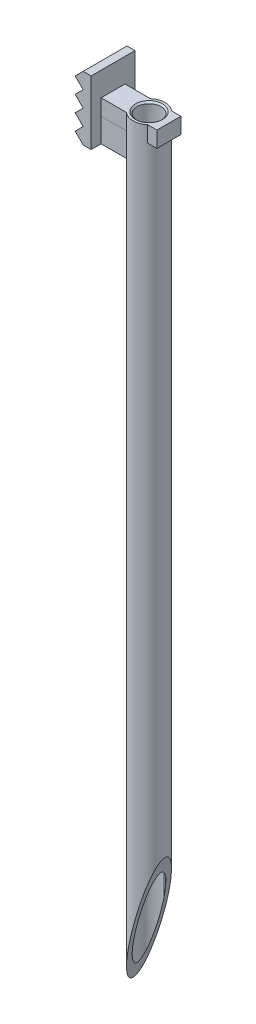
from build123d import *

# Parameters (mm, degrees)
SKETCH1_W                = 3.5
SKETCH1_H                = 1
BOSS_EXTRUDE3_DEPTH      = 0.75
SKETCH4_R                = 1
BOSS_EXTRUDE5_DEPTH      = 46.5
BOSS_EXTRUDE5_DEPTH_BACK = 1
SKETCH5_R                = 0.75
CUT_EXTRUDE1_DEPTH       = 18
SKETCH6_W                = 2.75
SKETCH6_H                = 4
BOSS_EXTRUDE6_DEPTH      = 1
CUT_EXTRUDE2_DEPTH       = 10
CUT_EXTRUDE4_DEPTH       = 2.75
CUT_EXTRUDE4_DEPTH_BACK  = 2
SKETCH10_R               = 0.75
CUT_EXTRUDE5_DEPTH       = 29
SKETCH11_R               = 0.4
BOSS_EXTRUDE7_DEPTH      = 1
SKETCH12_R               = 0.325
CUT_EXTRUDE6_DEPTH       = 35
FILLET1_R                = 0.025
FILLET2_R                = 0.025
FILLET3_R                = 0.25
FILLET4_R                = 0.1
SKETCH13_W               = 0.317975189
SKETCH13_H               = 1
BOSS_EXTRUDE8_DEPTH      = 0.375
SKETCH14_W               = 0.317975189
SKETCH14_H               = 1
BOSS_EXTRUDE9_DEPTH      = 0.375
BOSS_EXTRUDE10_REACH     = 6.182
SKETCH15_W               = 0.375
SKETCH15_H               = 1
BOSS_EXTRUDE11_REACH     = 6.182
SKETCH16_W               = 0.375
SKETCH16_H               = 1
SKETCH17_W               = 1.327975189
SKETCH17_H               = 1
BOSS_EXTRUDE12_DEPTH     = 0.375
BOSS_EXTRUDE13_REACH     = 4.172
SKETCH18_W               = 0.375
SKETCH18_H               = 1
SKETCH19_W               = 1.327975189
SKETCH19_H               = 1
BOSS_EXTRUDE14_DEPTH     = 0.375
BOSS_EXTRUDE15_REACH     = 4.172
SKETCH20_W               = 0.375
SKETCH20_H               = 1
BOSS_EXTRUDE16_DEPTH     = 1.5
CHAMFER1_SIZE            = 0.1


with BuildPart() as part:
    # Sketch1 → Boss-Extrude3 (new body)
    with BuildSketch(Plane.XY):
        with Locations((1.75, 0.5)):
            Rectangle(SKETCH1_W, SKETCH1_H)
    extrude(amount=BOSS_EXTRUDE3_DEPTH)

    # Sketch4 → Boss-Extrude5 (add, two sides)
    with BuildSketch(Plane.XZ) as boss_extrude5_sk:
        with Locations((2.255, 0.375)):
            Circle(SKETCH4_R)
    extrude(amount=BOSS_EXTRUDE5_DEPTH)
    extrude(boss_extrude5_sk.sketch, amount=-BOSS_EXTRUDE5_DEPTH_BACK)

    # Sketch5 → Cut-Extrude1 (cut)
    with BuildSketch(Plane.XZ.offset(46.5)):
        with Locations((2.255, 0.375)):
            Circle(SKETCH5_R)
    extrude(amount=-CUT_EXTRUDE1_DEPTH, mode=Mode.SUBTRACT)

    # Sketch6 → Boss-Extrude6 (add)
    with BuildSketch(Plane.ZY):
        with Locations((0.375, 0.5)):
            Rectangle(SKETCH6_W, SKETCH6_H)
    extrude(amount=BOSS_EXTRUDE6_DEPTH)

    # Sketch7 → Cut-Extrude2 (cut)
    with BuildSketch(Plane.XY.offset(1.75)):
        Polygon((-0.5, 2.5), (-1.357587954, 2.5), (-1.357587954, -1.5), (-0.5, -1.5), (-1, -1), (-0.5, -0.5), (-1, 0), (-0.5, 0.5), (-1, 1), (-0.5, 1.5), (-1, 2), align=None)
    extrude(amount=-CUT_EXTRUDE2_DEPTH, mode=Mode.SUBTRACT)

    # Sketch8 → Cut-Extrude4 (cut, two sides)
    with BuildSketch(Plane.XY) as cut_extrude4_sk:
        Polygon((1.255, -46.5), (3.255, -39), (3.255, -46.5), align=None)
    extrude(amount=CUT_EXTRUDE4_DEPTH, mode=Mode.SUBTRACT)
    extrude(cut_extrude4_sk.sketch, amount=-CUT_EXTRUDE4_DEPTH_BACK, mode=Mode.SUBTRACT)

    # Sketch10 → Cut-Extrude5 (cut)
    with BuildSketch(Plane(origin=(0, 1, 0), x_dir=(1, 0, 0), z_dir=(0, 1, 0))):
        with Locations((2.255, -0.375)):
            Circle(SKETCH10_R)
    extrude(amount=-CUT_EXTRUDE5_DEPTH, mode=Mode.SUBTRACT)

    # Sketch11 → Boss-Extrude7 (add)
    with BuildSketch(Plane(origin=(0, -28, 0), x_dir=(1, 0, 0), z_dir=(0, 1, 0))):
        with Locations((2.255, -0.375)):
            Circle(SKETCH11_R)
    extrude(amount=BOSS_EXTRUDE7_DEPTH)

    # Sketch12 → Cut-Extrude6 (cut)
    with BuildSketch(Plane(origin=(0, -27, 0), x_dir=(1, 0, 0), z_dir=(0, 1, 0))):
        with Locations((2.255, -0.375)):
            Circle(SKETCH12_R)
    extrude(amount=-CUT_EXTRUDE6_DEPTH, mode=Mode.SUBTRACT)

    # Fillet1
    fillet1_edges = [part.edges().sort_by_distance(p)[0] for p in [
        (1.93, -27, 0.375),
    ]]
    fillet(fillet1_edges, radius=FILLET1_R)

    # Fillet2
    fillet2_edges = [part.edges().sort_by_distance(p)[0] for p in [
        (1.855, -27, 0.375),
    ]]
    fillet(fillet2_edges, radius=FILLET2_R)

    # Fillet3
    fillet3_edges = [part.edges().sort_by_distance(p)[0] for p in [
        (1.505, -28.5, 0.375),
    ]]
    fillet(fillet3_edges, radius=FILLET3_R)

    # Fillet4
    fillet4_edges = [part.edges().sort_by_distance(p)[0] for p in [
        (1.93, -28.5, 0.375),
    ]]
    fillet(fillet4_edges, radius=FILLET4_R)

    # Sketch13 → Boss-Extrude8 (add)
    with BuildSketch(Plane(origin=(0, 0, 0), x_dir=(-1, 0, 0), z_dir=(0, 0, -1))):
        with Locations((-3.341012405, 0.5)):
            Rectangle(SKETCH13_W, SKETCH13_H)
    extrude(amount=BOSS_EXTRUDE8_DEPTH)

    # Sketch14 → Boss-Extrude9 (add)
    with BuildSketch(Plane.XY.offset(0.75)):
        with Locations((3.341012405, 0.5)):
            Rectangle(SKETCH14_W, SKETCH14_H)
    extrude(amount=BOSS_EXTRUDE9_DEPTH)

    # Sketch15 → Boss-Extrude10 (add, up to next)
    with BuildSketch(Plane.ZY.offset(-3.182024811), mode=Mode.PRIVATE) as boss_extrude10_sk1:
        with Locations((-0.1875, 0.5)):
            Rectangle(SKETCH15_W, SKETCH15_H)
    boss_extrude10_tool1 = extrude(boss_extrude10_sk1.sketch, amount=BOSS_EXTRUDE10_REACH, mode=Mode.PRIVATE) - part.part
    add(boss_extrude10_tool1.solids().sort_by_distance((3.182025, 0.5, -0.1875))[0])

    # Sketch16 → Boss-Extrude11 (add, up to next)
    with BuildSketch(Plane.ZY.offset(-3.182024811), mode=Mode.PRIVATE) as boss_extrude11_sk1:
        with Locations((0.9375, 0.5)):
            Rectangle(SKETCH16_W, SKETCH16_H)
    boss_extrude11_tool1 = extrude(boss_extrude11_sk1.sketch, amount=BOSS_EXTRUDE11_REACH, mode=Mode.PRIVATE) - part.part
    add(boss_extrude11_tool1.solids().sort_by_distance((3.182025, 0.5, 0.9375))[0])

    # Sketch17 → Boss-Extrude12 (add)
    with BuildSketch(Plane.XY.offset(0.75)):
        with Locations((0.663987595, 0.5)):
            Rectangle(SKETCH17_W, SKETCH17_H)
    extrude(amount=BOSS_EXTRUDE12_DEPTH)

    # Sketch18 → Boss-Extrude13 (add, up to next)
    with BuildSketch(Plane(origin=(1.327975189, 0, 0), x_dir=(0, 0, -1), z_dir=(1, 0, 0)), mode=Mode.PRIVATE) as boss_extrude13_sk1:
        with Locations((-0.9375, 0.5)):
            Rectangle(SKETCH18_W, SKETCH18_H)
    boss_extrude13_tool1 = extrude(boss_extrude13_sk1.sketch, amount=BOSS_EXTRUDE13_REACH, mode=Mode.PRIVATE) - part.part
    add(boss_extrude13_tool1.solids().sort_by_distance((1.327975, 0.5, 0.9375))[0])

    # Sketch19 → Boss-Extrude14 (add)
    with BuildSketch(Plane(origin=(0, 0, 0), x_dir=(-1, 0, 0), z_dir=(0, 0, -1))):
        with Locations((-0.663987595, 0.5)):
            Rectangle(SKETCH19_W, SKETCH19_H)
    extrude(amount=BOSS_EXTRUDE14_DEPTH)

    # Sketch20 → Boss-Extrude15 (add, up to next)
    with BuildSketch(Plane(origin=(1.327975189, 0, 0), x_dir=(0, 0, -1), z_dir=(1, 0, 0)), mode=Mode.PRIVATE) as boss_extrude15_sk1:
        with Locations((0.1875, 0.5)):
            Rectangle(SKETCH20_W, SKETCH20_H)
    boss_extrude15_tool1 = extrude(boss_extrude15_sk1.sketch, amount=BOSS_EXTRUDE15_REACH, mode=Mode.PRIVATE) - part.part
    add(boss_extrude15_tool1.solids().sort_by_distance((1.327975, 0.5, -0.1875))[0])

    # Chamfer1
    chamfer1_edges = [part.edges().sort_by_distance(p)[0] for p in [
        (1.505, 1, 0.375),
    ]]
    chamfer(chamfer1_edges, length=CHAMFER1_SIZE)


with BuildPart() as body_2:
    # Sketch21 → Boss-Extrude16 (new body)
    with BuildSketch(Plane.XZ):
        with BuildLine():
            Line((0, 1.125), (0, -0.375))
            Line((0, -0.375), (1.593562172, -0.375))
            ThreePointArc((1.593562172, -0.375), (1.255, 0.375), (1.593562172, 1.125))
            Line((1.593562172, 1.125), (0, 1.125))
        make_face()
    extrude(amount=BOSS_EXTRUDE16_DEPTH)


solid = Compound([part.part, body_2.part])
